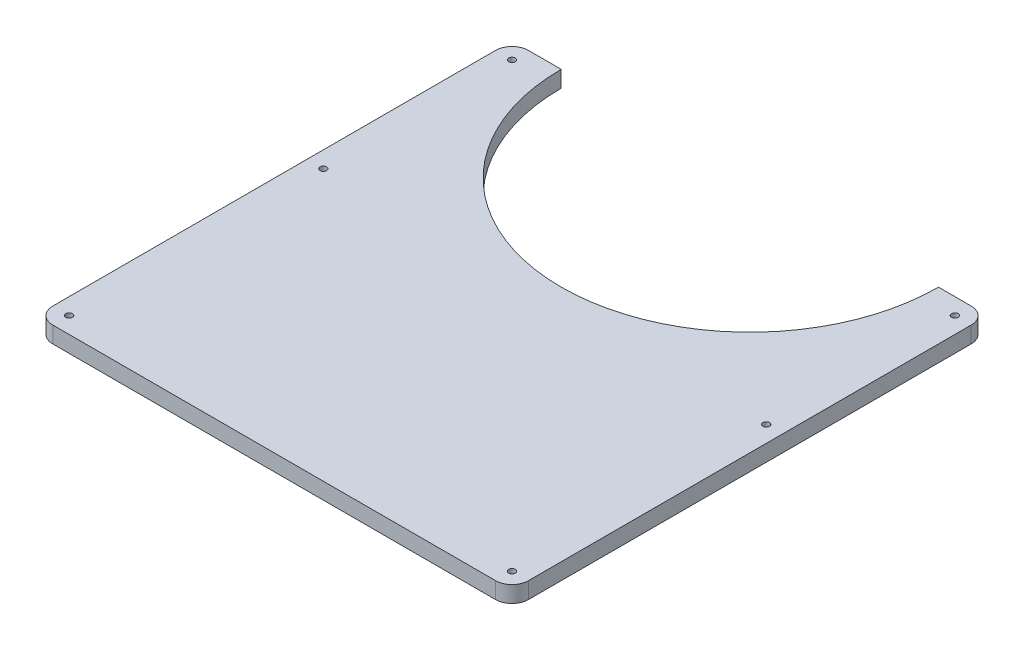
from build123d import *

# Parameters (mm, degrees)
BOSS_EXTRU_1_DEPTH      = 10
ESQUISSE3_R             = 2
ENL_V_MAT_EXTRU_1_DEPTH = 10
CONG_1_R                = 10
ESQUISSE4_R             = 2
ENL_V_MAT_EXTRU_2_DEPTH = 10
ESQUISSE6_R             = 6
ENL_V_MAT_EXTRU_4_DEPTH = 5


with BuildPart() as part:
    # Esquisse2 → Boss.-Extru.1 (new body)
    with BuildSketch(Plane(origin=(0, 0, 0), x_dir=(1, 0, 0), z_dir=(0, 1, 0))):
        with BuildLine():
            Line((0, 0), (290, 0))
            Line((290, 0), (290, 290))
            Line((290, 290), (260, 290))
            ThreePointArc((260, 290), (145, 175), (30, 290))
            Line((30, 290), (0, 290))
            Line((0, 290), (0, 0))
        make_face()
    extrude(amount=BOSS_EXTRU_1_DEPTH)

    # Esquisse3 → Enlèv. mat.-Extru.1 (cut)
    with BuildSketch(Plane(origin=(0, 10, 0), x_dir=(1, 0, 0), z_dir=(0, 1, 0))):
        with Locations((10, 280)):
            Circle(ESQUISSE3_R)
        with Locations((280, 280)):
            Circle(ESQUISSE3_R)
        with Locations((280, 10)):
            Circle(ESQUISSE3_R)
        with Locations((10, 10)):
            Circle(ESQUISSE3_R)
    extrude(amount=-ENL_V_MAT_EXTRU_1_DEPTH, mode=Mode.SUBTRACT)

    # Congé1
    cong_1_edges = [part.edges().sort_by_distance(p)[0] for p in [
        (0, 5, -290),
        (290, 5, -290),
        (290, 5, 0),
        (0, 5, 0),
    ]]
    fillet(cong_1_edges, radius=CONG_1_R)

    # Esquisse4 → Enlèv. mat.-Extru.2 (cut)
    with BuildSketch(Plane(origin=(0, 10, 0), x_dir=(1, 0, 0), z_dir=(0, 1, 0))):
        with Locations((10, 165)):
            Circle(ESQUISSE4_R)
        with Locations((280, 165)):
            Circle(ESQUISSE4_R)
    extrude(amount=-ENL_V_MAT_EXTRU_2_DEPTH, mode=Mode.SUBTRACT)

    # Esquisse6 → Enlèv. mat.-Extru.4 (cut)
    with BuildSketch(Plane.XZ):
        with Locations((10, -10)):
            Circle(ESQUISSE6_R)
        with Locations((280, -10)):
            Circle(ESQUISSE6_R)
        with Locations((280, -165)):
            Circle(ESQUISSE6_R)
        with Locations((280, -280)):
            Circle(ESQUISSE6_R)
        with Locations((10, -280)):
            Circle(ESQUISSE6_R)
        with Locations((10, -165)):
            Circle(ESQUISSE6_R)
    extrude(amount=-ENL_V_MAT_EXTRU_4_DEPTH, mode=Mode.SUBTRACT)


solid = part.part
